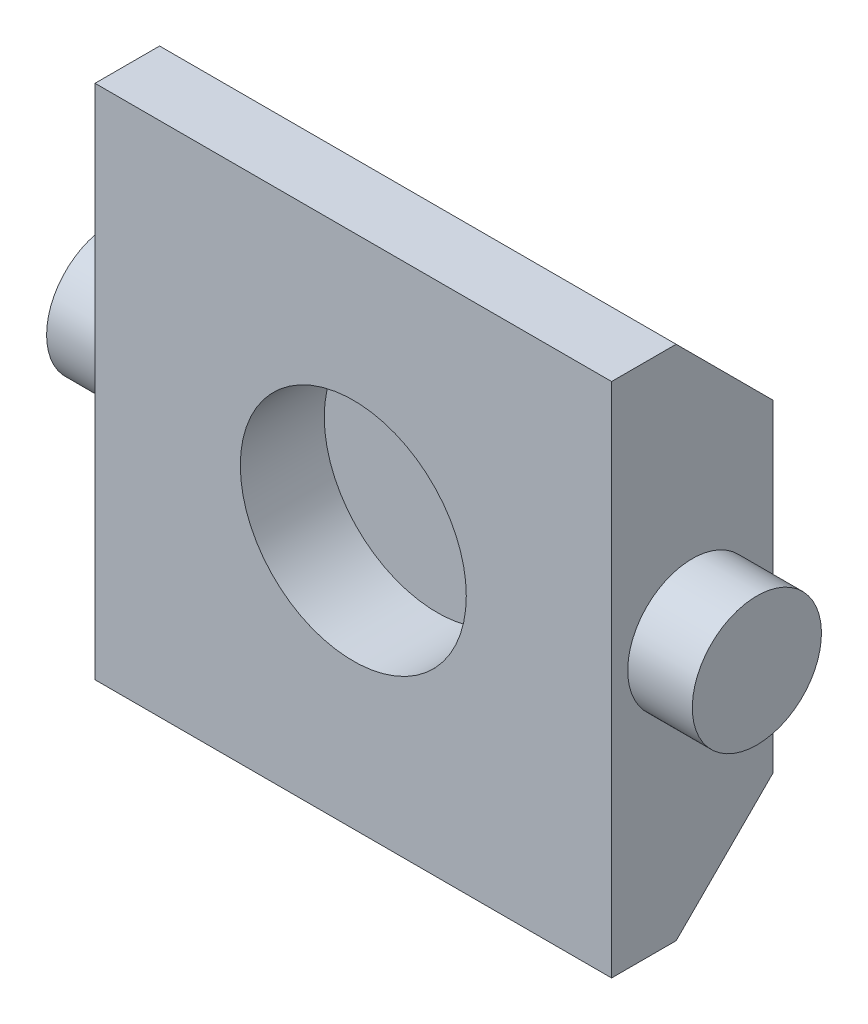
from build123d import *

# Parameters (mm, degrees)
SKETCH1_W          = 50.8
SKETCH1_H          = 50.8
EXTRUDE1_DEPTH     = 7.9375
SKETCH6_R          = 11.1125
CUT_EXTRUDE2_DEPTH = 8.255
SKETCH3_R          = 6.35
EXTRUDE3_DEPTH     = 6.35
CHAMFER1_SIZE      = 9.525


with BuildPart() as part:
    # Sketch1 → Extrude1 (new body, symmetric)
    with BuildSketch(Plane.XY):
        Rectangle(SKETCH1_W, SKETCH1_H)
    extrude(amount=EXTRUDE1_DEPTH, both=True)

    # Sketch6 → Cut-Extrude2 (cut)
    with BuildSketch(Plane.XY.offset(7.9375)):
        Circle(SKETCH6_R)
    extrude(amount=-CUT_EXTRUDE2_DEPTH, mode=Mode.SUBTRACT)

    # Sketch3 → Extrude3 (add)
    with BuildSketch(Plane.ZY.offset(25.4)):
        with Locations(Location((0, 0, 0), (0, 0, 90))):  # turned: the seam where the file's is
            Circle(SKETCH3_R)
    extrude3 = extrude(amount=EXTRUDE3_DEPTH)

    # Mirror2: Extrude3 across plane
    add(extrude3.mirror(Plane(origin=(0, 0, 0), x_dir=(0, 0, 1), z_dir=(1, 0, 0))))

    # Chamfer1
    chamfer1_edges = [part.edges().sort_by_distance(p)[0] for p in [
        (0, 25.4, -7.9375),
        (0, -25.4, -7.9375),
    ]]
    chamfer(chamfer1_edges, length=CHAMFER1_SIZE)


solid = part.part
